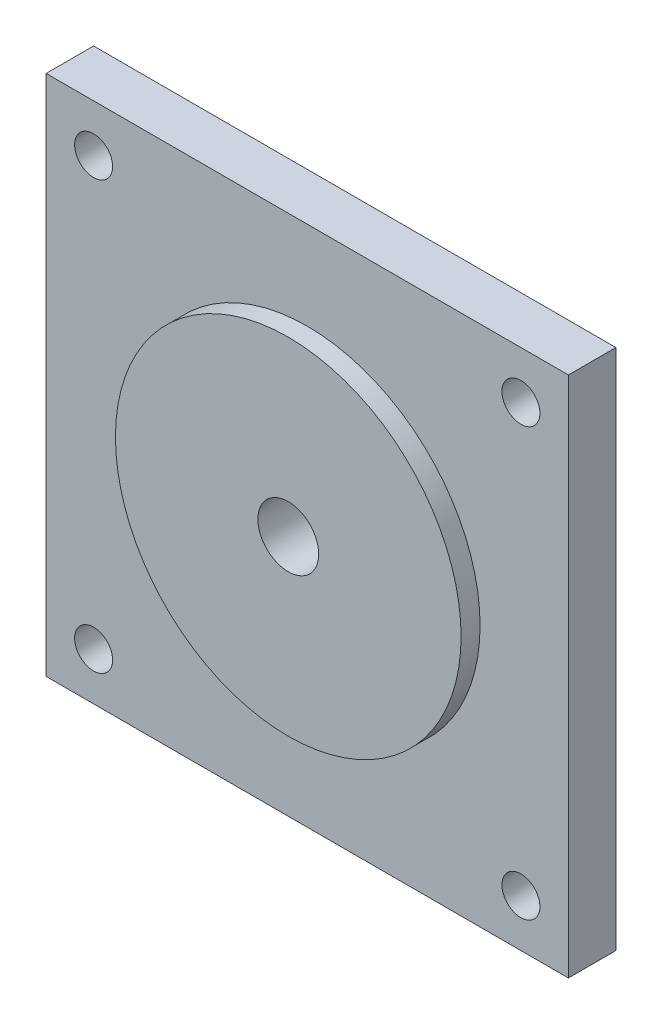
from build123d import *

# Parameters (mm, degrees)
SKETCH1_W           = 55
SKETCH1_H           = 55
SKETCH1_R           = 3.2
SKETCH1_R_2         = 2
BOSS_EXTRUDE1_DEPTH = 5
SKETCH2_R           = 18.2
SKETCH2_R_2         = 3.2
BOSS_EXTRUDE2_DEPTH = 2


with BuildPart() as part:
    # Sketch1 → Boss-Extrude1 (new body)
    with BuildSketch(Plane.XY):
        Rectangle(SKETCH1_W, SKETCH1_H)
        Circle(SKETCH1_R, mode=Mode.SUBTRACT)
        with Locations((-22.5, 22.5)):
            Circle(SKETCH1_R_2, mode=Mode.SUBTRACT)
        with Locations((22.5, 22.5)):
            Circle(SKETCH1_R_2, mode=Mode.SUBTRACT)
        with Locations((-22.5, -22.5)):
            Circle(SKETCH1_R_2, mode=Mode.SUBTRACT)
        with Locations((22.5, -22.5)):
            Circle(SKETCH1_R_2, mode=Mode.SUBTRACT)
    extrude(amount=BOSS_EXTRUDE1_DEPTH)

    # Sketch2 → Boss-Extrude2 (add)
    with BuildSketch(Plane.XY.offset(5)):
        Circle(SKETCH2_R)
        Circle(SKETCH2_R_2, mode=Mode.SUBTRACT)
    extrude(amount=BOSS_EXTRUDE2_DEPTH)


solid = part.part
